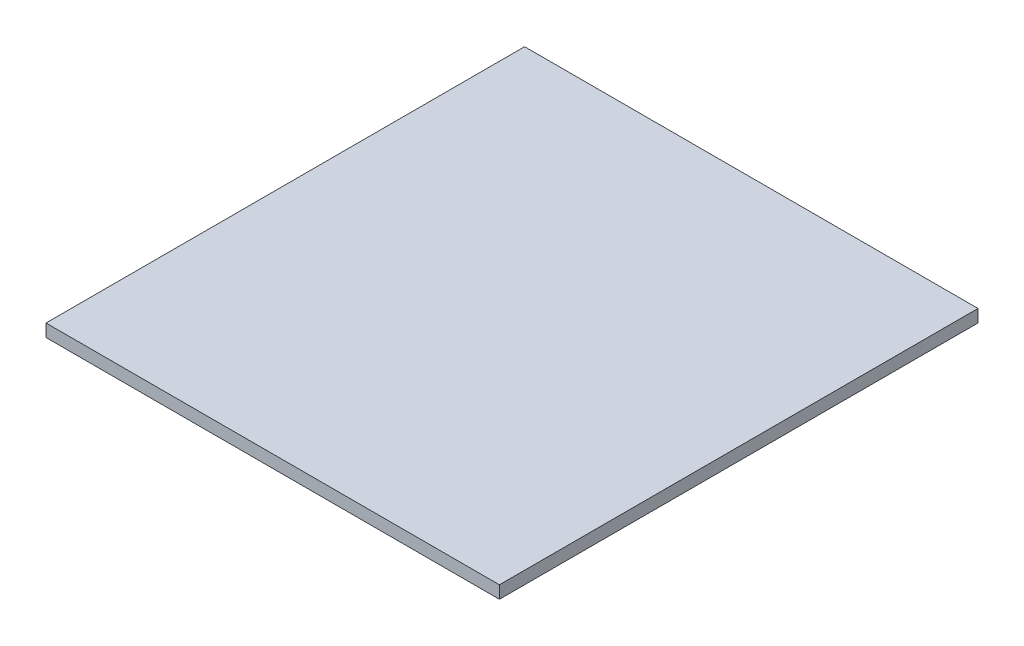
from build123d import *

# Parameters (mm, degrees)
SKETCH1_W           = 457.2
SKETCH1_H           = 482.6
BOSS_EXTRUDE1_DEPTH = 12.7


with BuildPart() as part:
    # Sketch1 → Boss-Extrude1 (new body)
    with BuildSketch(Plane(origin=(0, 0, 0), x_dir=(1, 0, 0), z_dir=(0, 1, 0))):
        Rectangle(SKETCH1_W, SKETCH1_H)
    extrude(amount=BOSS_EXTRUDE1_DEPTH)


solid = part.part
